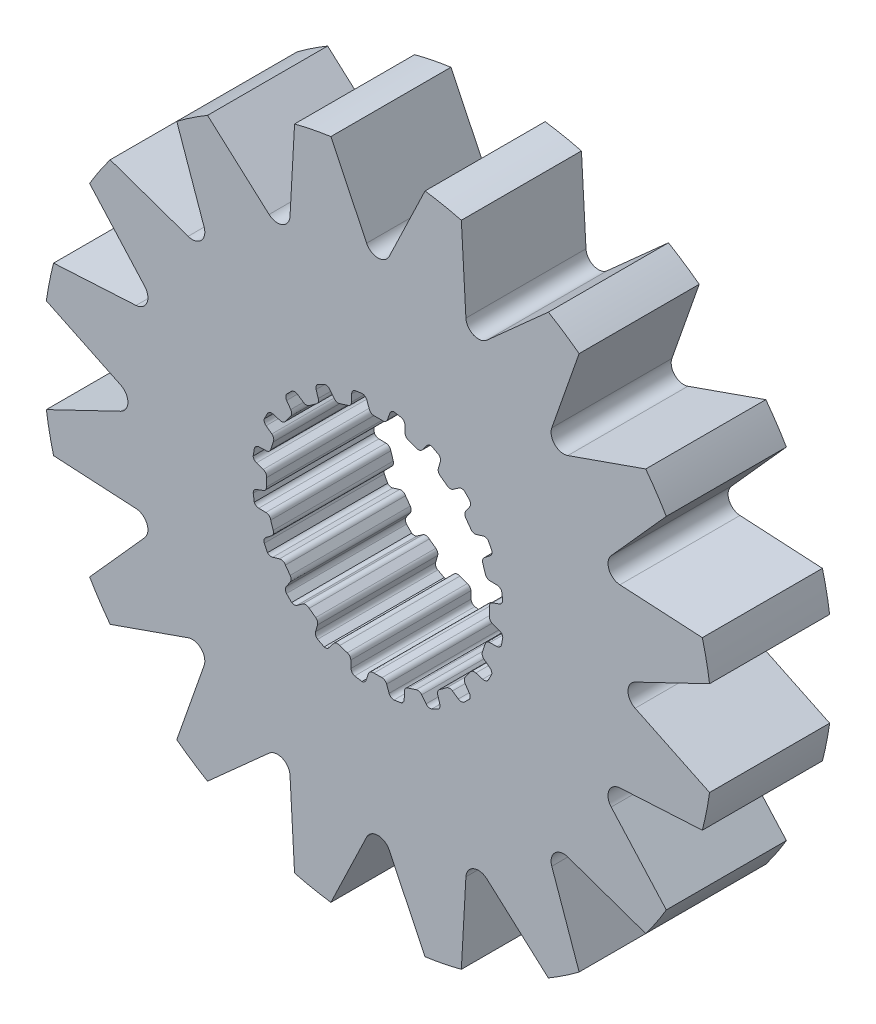
from build123d import *

# Parameters (mm, degrees)
SKETCH1_R           = 8.926200703
BOSS_EXTRUDE1_DEPTH = 1.6002
CUT_EXTRUDE1_DEPTH  = 3.2004


with BuildPart() as part:
    # Sketch1 → Boss-Extrude1 (new body, symmetric)
    with BuildSketch(Plane.XY):
        Circle(SKETCH1_R)
        with BuildLine():
            Line((-0.106949245, 2.969874934), (0.106949245, 2.969874934))
            ThreePointArc((0.106949245, 2.969874934), (0.196343213, 2.986924176), (0.253739238, 3.057547504))
            Line((0.253739238, 3.057547504), (0.315888147, 3.237526941))
            ThreePointArc((0.315888147, 3.237526941), (0.359032156, 3.298322911), (0.4281449, 3.326269005))
            Line((0.4281449, 3.326269005), (0.620027588, 3.2937547))
            ThreePointArc((0.620027588, 3.2937547), (0.689621142, 3.24802576), (0.718272212, 3.169836791))
            Line((0.718272212, 3.169836791), (0.724389167, 2.979527391))
            ThreePointArc((0.724389167, 2.979527391), (0.750934762, 2.9040661), (0.816027049, 2.857568043))
            Line((0.816027049, 2.857568043), (1.019456602, 2.791469774))
            ThreePointArc((1.019456602, 2.791469774), (1.109743823, 2.780060312), (1.186154496, 2.829490741))
            Line((1.186154496, 2.829490741), (1.300878326, 2.981456288))
            ThreePointArc((1.300878326, 2.981456288), (1.360697704, 3.02594446), (1.435063648, 3.031165762))
            Line((1.435063648, 3.031165762), (1.607507455, 2.940947809))
            ThreePointArc((1.607507455, 2.940947809), (1.659563839, 2.875951412), (1.662650905, 2.792735615))
            Line((1.662650905, 2.792735615), (1.609659636, 2.609850378))
            ThreePointArc((1.609659636, 2.609850378), (1.611587176, 2.529879385), (1.659124931, 2.465542482))
            Line((1.659124931, 2.465542482), (1.832172444, 2.339816104))
            ThreePointArc((1.832172444, 2.339816104), (1.914514976, 2.301064775), (2.002460687, 2.32446371))
            Line((2.002460687, 2.32446371), (2.158529469, 2.433539921))
            ThreePointArc((2.158529469, 2.433539921), (2.229168681, 2.457365482), (2.301508367, 2.439350895))
            Line((2.301508367, 2.439350895), (2.437633293, 2.300260456))
            ThreePointArc((2.437633293, 2.300260456), (2.467056864, 2.222358901), (2.444277744, 2.14226202))
            Line((2.444277744, 2.14226202), (2.337365406, 1.984703026))
            ThreePointArc((2.337365406, 1.984703026), (2.314486209, 1.908050449), (2.339816104, 1.832172444))
            Line((2.339816104, 1.832172444), (2.465542482, 1.659124931))
            ThreePointArc((2.465542482, 1.659124931), (2.531880064, 1.596824985), (2.622752074, 1.591901975))
            Line((2.622752074, 1.591901975), (2.804888709, 1.64741171))
            ThreePointArc((2.804888709, 1.64741171), (2.879433095, 1.648242449), (2.942665411, 1.608755366))
            Line((2.942665411, 1.608755366), (3.0291466, 1.434407582))
            ThreePointArc((3.0291466, 1.434407582), (3.033057175, 1.351226417), (2.986641646, 1.282088892))
            Line((2.986641646, 1.282088892), (2.836273564, 1.165279113))
            ThreePointArc((2.836273564, 1.165279113), (2.790827206, 1.099448241), (2.791469774, 1.019456602))
            Line((2.791469774, 1.019456602), (2.857568043, 0.816027049))
            ThreePointArc((2.857568043, 0.816027049), (2.901407091, 0.736276839), (2.986310214, 0.703513784))
            Line((2.986310214, 0.703513784), (3.1766859, 0.700023363))
            ThreePointArc((3.1766859, 0.700023363), (3.247838536, 0.677777961), (3.295773863, 0.620683653))
            Line((3.295773863, 0.620683653), (3.324145932, 0.4281449))
            ThreePointArc((3.324145932, 0.4281449), (3.302160717, 0.347826477), (3.236652255, 0.29641597))
            Line((3.236652255, 0.29641597), (3.057547504, 0.231789562))
            ThreePointArc((3.057547504, 0.231789562), (2.993982591, 0.183224379), (2.969874934, 0.106949245))
            Line((2.969874934, 0.106949245), (2.969874934, -0.106949245))
            ThreePointArc((2.969874934, -0.106949245), (2.986924176, -0.196343213), (3.057547504, -0.253739238))
            Line((3.057547504, -0.253739238), (3.237526941, -0.315888147))
            ThreePointArc((3.237526941, -0.315888147), (3.298322911, -0.359032156), (3.326269005, -0.4281449))
            Line((3.326269005, -0.4281449), (3.2937547, -0.620027588))
            ThreePointArc((3.2937547, -0.620027588), (3.24802576, -0.689621142), (3.169836791, -0.718272212))
            Line((3.169836791, -0.718272212), (2.979527391, -0.724389167))
            ThreePointArc((2.979527391, -0.724389167), (2.9040661, -0.750934762), (2.857568043, -0.816027049))
            Line((2.857568043, -0.816027049), (2.791469774, -1.019456602))
            ThreePointArc((2.791469774, -1.019456602), (2.780060312, -1.109743823), (2.829490741, -1.186154496))
            Line((2.829490741, -1.186154496), (2.981456288, -1.300878326))
            ThreePointArc((2.981456288, -1.300878326), (3.02594446, -1.360697704), (3.031165762, -1.435063648))
            Line((3.031165762, -1.435063648), (2.940947809, -1.607507455))
            ThreePointArc((2.940947809, -1.607507455), (2.875951412, -1.659563839), (2.792735615, -1.662650905))
            Line((2.792735615, -1.662650905), (2.609850378, -1.609659636))
            ThreePointArc((2.609850378, -1.609659636), (2.529879385, -1.611587176), (2.465542482, -1.659124931))
            Line((2.465542482, -1.659124931), (2.339816104, -1.832172444))
            ThreePointArc((2.339816104, -1.832172444), (2.301064775, -1.914514976), (2.32446371, -2.002460687))
            Line((2.32446371, -2.002460687), (2.433539921, -2.158529469))
            ThreePointArc((2.433539921, -2.158529469), (2.457365482, -2.229168681), (2.439350895, -2.301508367))
            Line((2.439350895, -2.301508367), (2.300260456, -2.437633293))
            ThreePointArc((2.300260456, -2.437633293), (2.222358901, -2.467056864), (2.14226202, -2.444277744))
            Line((2.14226202, -2.444277744), (1.984703026, -2.337365406))
            ThreePointArc((1.984703026, -2.337365406), (1.908050449, -2.314486209), (1.832172444, -2.339816104))
            Line((1.832172444, -2.339816104), (1.659124931, -2.465542482))
            ThreePointArc((1.659124931, -2.465542482), (1.596824985, -2.531880064), (1.591901975, -2.622752074))
            Line((1.591901975, -2.622752074), (1.64741171, -2.804888709))
            ThreePointArc((1.64741171, -2.804888709), (1.648242449, -2.879433095), (1.608755366, -2.942665411))
            Line((1.608755366, -2.942665411), (1.434407582, -3.0291466))
            ThreePointArc((1.434407582, -3.0291466), (1.351226417, -3.033057175), (1.282088892, -2.986641646))
            Line((1.282088892, -2.986641646), (1.165279113, -2.836273564))
            ThreePointArc((1.165279113, -2.836273564), (1.099448241, -2.790827206), (1.019456602, -2.791469774))
            Line((1.019456602, -2.791469774), (0.816027049, -2.857568043))
            ThreePointArc((0.816027049, -2.857568043), (0.736276839, -2.901407091), (0.703513784, -2.986310214))
            Line((0.703513784, -2.986310214), (0.700023363, -3.1766859))
            ThreePointArc((0.700023363, -3.1766859), (0.677777961, -3.247838536), (0.620683653, -3.295773863))
            Line((0.620683653, -3.295773863), (0.4281449, -3.324145932))
            ThreePointArc((0.4281449, -3.324145932), (0.347826477, -3.302160717), (0.29641597, -3.236652255))
            Line((0.29641597, -3.236652255), (0.231789562, -3.057547504))
            ThreePointArc((0.231789562, -3.057547504), (0.183224379, -2.993982591), (0.106949245, -2.969874934))
            Line((0.106949245, -2.969874934), (-0.106949245, -2.969874934))
            ThreePointArc((-0.106949245, -2.969874934), (-0.196343213, -2.986924176), (-0.253739238, -3.057547504))
            Line((-0.253739238, -3.057547504), (-0.315888147, -3.237526941))
            ThreePointArc((-0.315888147, -3.237526941), (-0.359032156, -3.298322911), (-0.4281449, -3.326269005))
            Line((-0.4281449, -3.326269005), (-0.620027588, -3.2937547))
            ThreePointArc((-0.620027588, -3.2937547), (-0.689621142, -3.24802576), (-0.718272212, -3.169836791))
            Line((-0.718272212, -3.169836791), (-0.724389167, -2.979527391))
            ThreePointArc((-0.724389167, -2.979527391), (-0.750934762, -2.9040661), (-0.816027049, -2.857568043))
            Line((-0.816027049, -2.857568043), (-1.019456602, -2.791469774))
            ThreePointArc((-1.019456602, -2.791469774), (-1.109743823, -2.780060312), (-1.186154496, -2.829490741))
            Line((-1.186154496, -2.829490741), (-1.300878326, -2.981456288))
            ThreePointArc((-1.300878326, -2.981456288), (-1.360697704, -3.02594446), (-1.435063648, -3.031165762))
            Line((-1.435063648, -3.031165762), (-1.607507455, -2.940947809))
            ThreePointArc((-1.607507455, -2.940947809), (-1.659563839, -2.875951412), (-1.662650905, -2.792735615))
            Line((-1.662650905, -2.792735615), (-1.609659636, -2.609850378))
            ThreePointArc((-1.609659636, -2.609850378), (-1.611587176, -2.529879385), (-1.659124931, -2.465542482))
            Line((-1.659124931, -2.465542482), (-1.832172444, -2.339816104))
            ThreePointArc((-1.832172444, -2.339816104), (-1.914514976, -2.301064775), (-2.002460687, -2.32446371))
            Line((-2.002460687, -2.32446371), (-2.158529469, -2.433539921))
            ThreePointArc((-2.158529469, -2.433539921), (-2.229168681, -2.457365482), (-2.301508367, -2.439350895))
            Line((-2.301508367, -2.439350895), (-2.437633293, -2.300260456))
            ThreePointArc((-2.437633293, -2.300260456), (-2.467056864, -2.222358901), (-2.444277744, -2.14226202))
            Line((-2.444277744, -2.14226202), (-2.337365406, -1.984703026))
            ThreePointArc((-2.337365406, -1.984703026), (-2.314486209, -1.908050449), (-2.339816104, -1.832172444))
            Line((-2.339816104, -1.832172444), (-2.465542482, -1.659124931))
            ThreePointArc((-2.465542482, -1.659124931), (-2.531880064, -1.596824985), (-2.622752074, -1.591901975))
            Line((-2.622752074, -1.591901975), (-2.804888709, -1.64741171))
            ThreePointArc((-2.804888709, -1.64741171), (-2.879433095, -1.648242449), (-2.942665411, -1.608755366))
            Line((-2.942665411, -1.608755366), (-3.0291466, -1.434407582))
            ThreePointArc((-3.0291466, -1.434407582), (-3.033057175, -1.351226417), (-2.986641646, -1.282088892))
            Line((-2.986641646, -1.282088892), (-2.836273564, -1.165279113))
            ThreePointArc((-2.836273564, -1.165279113), (-2.790827206, -1.099448241), (-2.791469774, -1.019456602))
            Line((-2.791469774, -1.019456602), (-2.857568043, -0.816027049))
            ThreePointArc((-2.857568043, -0.816027049), (-2.901407091, -0.736276839), (-2.986310214, -0.703513784))
            Line((-2.986310214, -0.703513784), (-3.1766859, -0.700023363))
            ThreePointArc((-3.1766859, -0.700023363), (-3.247838536, -0.677777961), (-3.295773863, -0.620683653))
            Line((-3.295773863, -0.620683653), (-3.324145932, -0.4281449))
            ThreePointArc((-3.324145932, -0.4281449), (-3.302160717, -0.347826477), (-3.236652255, -0.29641597))
            Line((-3.236652255, -0.29641597), (-3.057547504, -0.231789562))
            ThreePointArc((-3.057547504, -0.231789562), (-2.993982591, -0.183224379), (-2.969874934, -0.106949245))
            Line((-2.969874934, -0.106949245), (-2.969874934, 0.106949245))
            ThreePointArc((-2.969874934, 0.106949245), (-2.986924176, 0.196343213), (-3.057547504, 0.253739238))
            Line((-3.057547504, 0.253739238), (-3.237526941, 0.315888147))
            ThreePointArc((-3.237526941, 0.315888147), (-3.298322911, 0.359032156), (-3.326269005, 0.4281449))
            Line((-3.326269005, 0.4281449), (-3.2937547, 0.620027588))
            ThreePointArc((-3.2937547, 0.620027588), (-3.24802576, 0.689621142), (-3.169836791, 0.718272212))
            Line((-3.169836791, 0.718272212), (-2.979527391, 0.724389167))
            ThreePointArc((-2.979527391, 0.724389167), (-2.9040661, 0.750934762), (-2.857568043, 0.816027049))
            Line((-2.857568043, 0.816027049), (-2.791469774, 1.019456602))
            ThreePointArc((-2.791469774, 1.019456602), (-2.780060312, 1.109743823), (-2.829490741, 1.186154496))
            Line((-2.829490741, 1.186154496), (-2.981456288, 1.300878326))
            ThreePointArc((-2.981456288, 1.300878326), (-3.02594446, 1.360697704), (-3.031165762, 1.435063648))
            Line((-3.031165762, 1.435063648), (-2.940947809, 1.607507455))
            ThreePointArc((-2.940947809, 1.607507455), (-2.875951412, 1.659563839), (-2.792735615, 1.662650905))
            Line((-2.792735615, 1.662650905), (-2.609850378, 1.609659636))
            ThreePointArc((-2.609850378, 1.609659636), (-2.529879385, 1.611587176), (-2.465542482, 1.659124931))
            Line((-2.465542482, 1.659124931), (-2.339816104, 1.832172444))
            ThreePointArc((-2.339816104, 1.832172444), (-2.301064775, 1.914514976), (-2.32446371, 2.002460687))
            Line((-2.32446371, 2.002460687), (-2.433539921, 2.158529469))
            ThreePointArc((-2.433539921, 2.158529469), (-2.457365482, 2.229168681), (-2.439350895, 2.301508367))
            Line((-2.439350895, 2.301508367), (-2.300260456, 2.437633293))
            ThreePointArc((-2.300260456, 2.437633293), (-2.222358901, 2.467056864), (-2.14226202, 2.444277744))
            Line((-2.14226202, 2.444277744), (-1.984703026, 2.337365406))
            ThreePointArc((-1.984703026, 2.337365406), (-1.908050449, 2.314486209), (-1.832172444, 2.339816104))
            Line((-1.832172444, 2.339816104), (-1.659124931, 2.465542482))
            ThreePointArc((-1.659124931, 2.465542482), (-1.596824985, 2.531880064), (-1.591901975, 2.622752074))
            Line((-1.591901975, 2.622752074), (-1.64741171, 2.804888709))
            ThreePointArc((-1.64741171, 2.804888709), (-1.648242449, 2.879433095), (-1.608755366, 2.942665411))
            Line((-1.608755366, 2.942665411), (-1.434407582, 3.0291466))
            ThreePointArc((-1.434407582, 3.0291466), (-1.351226417, 3.033057175), (-1.282088892, 2.986641646))
            Line((-1.282088892, 2.986641646), (-1.165279113, 2.836273564))
            ThreePointArc((-1.165279113, 2.836273564), (-1.099448241, 2.790827206), (-1.019456602, 2.791469774))
            Line((-1.019456602, 2.791469774), (-0.816027049, 2.857568043))
            ThreePointArc((-0.816027049, 2.857568043), (-0.736276839, 2.901407091), (-0.703513784, 2.986310214))
            Line((-0.703513784, 2.986310214), (-0.700023363, 3.1766859))
            ThreePointArc((-0.700023363, 3.1766859), (-0.677777961, 3.247838536), (-0.620683653, 3.295773863))
            Line((-0.620683653, 3.295773863), (-0.4281449, 3.324145932))
            ThreePointArc((-0.4281449, 3.324145932), (-0.347826477, 3.302160717), (-0.29641597, 3.236652255))
            Line((-0.29641597, 3.236652255), (-0.231789562, 3.057547504))
            ThreePointArc((-0.231789562, 3.057547504), (-0.183224379, 2.993982591), (-0.106949245, 2.969874934))
        make_face(mode=Mode.SUBTRACT)
    extrude(amount=BOSS_EXTRUDE1_DEPTH, both=True)

    # Sketch2 → Cut-Extrude1 (cut)
    with BuildSketch(Plane.XY.offset(1.6002)):
        with BuildLine():
            Line((-1.255122678, 8.837518093), (-0.301897322, 6.853917937))
            ThreePointArc((-0.301897322, 6.853917937), (0, 6.664048588), (0.301897322, 6.853917937))
            Line((0.301897322, 6.853917937), (1.255122678, 8.837518093))
            ThreePointArc((1.255122678, 8.837518093), (0, 8.926200703), (-1.255122678, 8.837518093))
        make_face()
        with BuildLine():
            Line((4.54155391, 7.68448743), (2.901797598, 6.216663396))
            ThreePointArc((2.901797598, 6.216663396), (2.550220987, 6.156778094), (2.343964085, 6.447725603))
            Line((2.343964085, 6.447725603), (2.222389605, 8.645116739))
            ThreePointArc((2.222389605, 8.645116739), (3.415909123, 8.246734132), (4.54155391, 7.68448743))
        make_face()
        with BuildLine():
            Line((7.136574729, 5.361563216), (5.059925495, 4.632978207))
            ThreePointArc((5.059925495, 4.632978207), (4.712193947, 4.712193947), (4.632978207, 5.059925495))
            Line((4.632978207, 5.059925495), (5.361563216, 7.136574729))
            ThreePointArc((5.361563216, 7.136574729), (6.311777047, 6.311777047), (7.136574729, 5.361563216))
        make_face()
        with BuildLine():
            Line((8.645116739, 2.222389605), (6.447725603, 2.343964085))
            ThreePointArc((6.447725603, 2.343964085), (6.156778094, 2.550220987), (6.216663396, 2.901797598))
            Line((6.216663396, 2.901797598), (7.68448743, 4.54155391))
            ThreePointArc((7.68448743, 4.54155391), (8.246734132, 3.415909123), (8.645116739, 2.222389605))
        make_face()
        with BuildLine():
            Line((8.837518093, -1.255122678), (6.853917937, -0.301897322))
            ThreePointArc((6.853917937, -0.301897322), (6.664048588, 0), (6.853917937, 0.301897322))
            Line((6.853917937, 0.301897322), (8.837518093, 1.255122678))
            ThreePointArc((8.837518093, 1.255122678), (8.926200703, 0), (8.837518093, -1.255122678))
        make_face()
        with BuildLine():
            Line((7.68448743, -4.54155391), (6.216663396, -2.901797598))
            ThreePointArc((6.216663396, -2.901797598), (6.156778094, -2.550220987), (6.447725603, -2.343964085))
            Line((6.447725603, -2.343964085), (8.645116739, -2.222389605))
            ThreePointArc((8.645116739, -2.222389605), (8.246734132, -3.415909123), (7.68448743, -4.54155391))
        make_face()
        with BuildLine():
            Line((5.361563216, -7.136574729), (4.632978207, -5.059925495))
            ThreePointArc((4.632978207, -5.059925495), (4.712193947, -4.712193947), (5.059925495, -4.632978207))
            Line((5.059925495, -4.632978207), (7.136574729, -5.361563216))
            ThreePointArc((7.136574729, -5.361563216), (6.311777047, -6.311777047), (5.361563216, -7.136574729))
        make_face()
        with BuildLine():
            Line((2.222389605, -8.645116739), (2.343964085, -6.447725603))
            ThreePointArc((2.343964085, -6.447725603), (2.550220987, -6.156778094), (2.901797598, -6.216663396))
            Line((2.901797598, -6.216663396), (4.54155391, -7.68448743))
            ThreePointArc((4.54155391, -7.68448743), (3.415909123, -8.246734132), (2.222389605, -8.645116739))
        make_face()
        with BuildLine():
            Line((-1.255122678, -8.837518093), (-0.301897322, -6.853917937))
            ThreePointArc((-0.301897322, -6.853917937), (0, -6.664048588), (0.301897322, -6.853917937))
            Line((0.301897322, -6.853917937), (1.255122678, -8.837518093))
            ThreePointArc((1.255122678, -8.837518093), (0, -8.926200703), (-1.255122678, -8.837518093))
        make_face()
        with BuildLine():
            Line((-4.54155391, -7.68448743), (-2.901797598, -6.216663396))
            ThreePointArc((-2.901797598, -6.216663396), (-2.550220987, -6.156778094), (-2.343964085, -6.447725603))
            Line((-2.343964085, -6.447725603), (-2.222389605, -8.645116739))
            ThreePointArc((-2.222389605, -8.645116739), (-3.415909123, -8.246734132), (-4.54155391, -7.68448743))
        make_face()
        with BuildLine():
            Line((-7.136574729, -5.361563216), (-5.059925495, -4.632978207))
            ThreePointArc((-5.059925495, -4.632978207), (-4.712193947, -4.712193947), (-4.632978207, -5.059925495))
            Line((-4.632978207, -5.059925495), (-5.361563216, -7.136574729))
            ThreePointArc((-5.361563216, -7.136574729), (-6.311777047, -6.311777047), (-7.136574729, -5.361563216))
        make_face()
        with BuildLine():
            Line((-8.645116739, -2.222389605), (-6.447725603, -2.343964085))
            ThreePointArc((-6.447725603, -2.343964085), (-6.156778094, -2.550220987), (-6.216663396, -2.901797598))
            Line((-6.216663396, -2.901797598), (-7.68448743, -4.54155391))
            ThreePointArc((-7.68448743, -4.54155391), (-8.246734132, -3.415909123), (-8.645116739, -2.222389605))
        make_face()
        with BuildLine():
            Line((-8.837518093, 1.255122678), (-6.853917937, 0.301897322))
            ThreePointArc((-6.853917937, 0.301897322), (-6.664048588, 0), (-6.853917937, -0.301897322))
            Line((-6.853917937, -0.301897322), (-8.837518093, -1.255122678))
            ThreePointArc((-8.837518093, -1.255122678), (-8.926200703, 0), (-8.837518093, 1.255122678))
        make_face()
        with BuildLine():
            Line((-7.68448743, 4.54155391), (-6.216663396, 2.901797598))
            ThreePointArc((-6.216663396, 2.901797598), (-6.156778094, 2.550220987), (-6.447725603, 2.343964085))
            Line((-6.447725603, 2.343964085), (-8.645116739, 2.222389605))
            ThreePointArc((-8.645116739, 2.222389605), (-8.246734132, 3.415909123), (-7.68448743, 4.54155391))
        make_face()
        with BuildLine():
            Line((-5.361563216, 7.136574729), (-4.632978207, 5.059925495))
            ThreePointArc((-4.632978207, 5.059925495), (-4.712193947, 4.712193947), (-5.059925495, 4.632978207))
            Line((-5.059925495, 4.632978207), (-7.136574729, 5.361563216))
            ThreePointArc((-7.136574729, 5.361563216), (-6.311777047, 6.311777047), (-5.361563216, 7.136574729))
        make_face()
        with BuildLine():
            Line((-2.222389605, 8.645116739), (-2.343964085, 6.447725603))
            ThreePointArc((-2.343964085, 6.447725603), (-2.550220987, 6.156778094), (-2.901797598, 6.216663396))
            Line((-2.901797598, 6.216663396), (-4.54155391, 7.68448743))
            ThreePointArc((-4.54155391, 7.68448743), (-3.415909123, 8.246734132), (-2.222389605, 8.645116739))
        make_face()
    extrude(amount=-CUT_EXTRUDE1_DEPTH, mode=Mode.SUBTRACT)


solid = part.part
